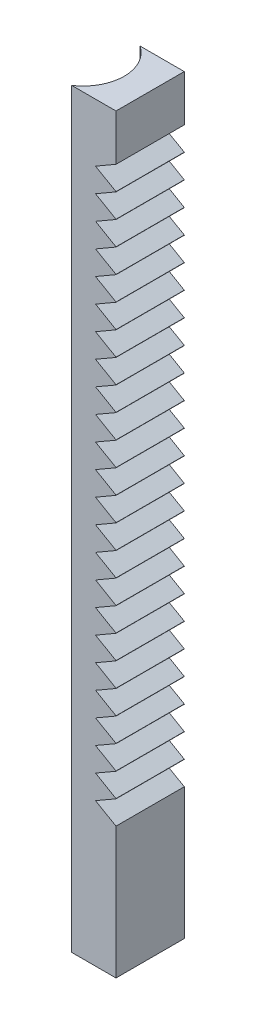
from build123d import *

# Parameters (mm, degrees)
BOSS_EXTRUDE1_DEPTH = 550
CUT_EXTRUDE1_DEPTH  = 73
BOSS_EXTRUDE2_DEPTH = 550


with BuildPart() as part:
    # Sketch1 → Boss-Extrude1 (new body)
    with BuildSketch(Plane(origin=(0, 0, 0), x_dir=(1, 0, 0), z_dir=(0, 1, 0))):
        with BuildLine():
            Line((43.301270189, -25), (69, -25))
            Line((69, -25), (69, 25))
            Line((69, 25), (43.301270189, 25))
            ThreePointArc((43.301270189, 25), (50, 0), (43.301270189, -25))
        make_face()
    extrude(amount=BOSS_EXTRUDE1_DEPTH)

    # Sketch2 → Cut-Extrude1 (cut)
    with BuildSketch(Plane.XY.offset(25)):
        Polygon((54, 489.993192311), (76.5, 477.002811254), (76.5, 502.983573367), align=None)
        Polygon((54, 507.493192311), (76.5, 494.502811254), (76.5, 520.483573367), align=None)
        Polygon((54, 472.493192311), (76.5, 459.502811254), (76.5, 485.483573367), align=None)
        Polygon((54, 454.993192311), (76.5, 442.002811254), (76.5, 467.983573367), align=None)
        Polygon((54, 437.493192311), (76.5, 424.502811254), (76.5, 450.483573367), align=None)
        Polygon((54, 419.993192311), (76.5, 407.002811254), (76.5, 432.983573367), align=None)
        Polygon((54, 402.493192311), (76.5, 389.502811254), (76.5, 415.483573367), align=None)
        Polygon((54, 384.993192311), (76.5, 372.002811254), (76.5, 397.983573367), align=None)
        Polygon((54, 367.493192311), (76.5, 354.502811254), (76.5, 380.483573367), align=None)
        Polygon((54, 349.993192311), (76.5, 337.002811254), (76.5, 362.983573367), align=None)
        Polygon((54, 332.493192311), (76.5, 319.502811254), (76.5, 345.483573367), align=None)
        Polygon((54, 314.993192311), (76.5, 302.002811254), (76.5, 327.983573367), align=None)
        Polygon((54, 297.493192311), (76.5, 284.502811254), (76.5, 310.483573367), align=None)
        Polygon((54, 279.993192311), (76.5, 267.002811254), (76.5, 292.983573367), align=None)
        Polygon((54, 262.493192311), (76.5, 249.502811254), (76.5, 275.483573367), align=None)
        Polygon((54, 244.993192311), (76.5, 232.002811254), (76.5, 257.983573367), align=None)
        Polygon((54, 227.493192311), (76.5, 214.502811254), (76.5, 240.483573367), align=None)
        Polygon((54, 209.993192311), (76.5, 197.002811254), (76.5, 222.983573367), align=None)
        Polygon((54, 192.493192311), (76.5, 179.502811254), (76.5, 205.483573367), align=None)
        Polygon((54, 174.993192311), (76.5, 162.002811254), (76.5, 187.983573367), align=None)
        Polygon((54, 157.493192311), (76.5, 144.502811254), (76.5, 170.483573367), align=None)
        Polygon((54, 139.993192311), (76.5, 127.002811254), (76.5, 152.983573367), align=None)
        Polygon((54, 122.493192311), (76.5, 109.502811254), (76.5, 135.483573367), align=None)
        Polygon((54, 104.993192311), (76.5, 92.002811254), (76.5, 117.983573367), align=None)
    extrude(amount=-CUT_EXTRUDE1_DEPTH, mode=Mode.SUBTRACT)

    # Sketch3 → Boss-Extrude2 (add)
    with BuildSketch(Plane(origin=(0, 550, 0), x_dir=(1, 0, 0), z_dir=(0, 1, 0))):
        with BuildLine():
            ThreePointArc((43.301270189, -25), (48.296291314, -12.940952255), (50, 0))
            ThreePointArc((50, 0), (46.433820369, -14.186371655), (36.583123952, -25))
            Line((36.583123952, -25), (43.301270189, -25))
        make_face()
        with BuildLine():
            ThreePointArc((50, 0), (48.296291314, 12.940952255), (43.301270189, 25))
            Line((43.301270189, 25), (36.583123952, 25))
            ThreePointArc((36.583123952, 25), (46.433820369, 14.186371655), (50, 0))
        make_face()
    extrude(amount=-BOSS_EXTRUDE2_DEPTH)


solid = part.part
